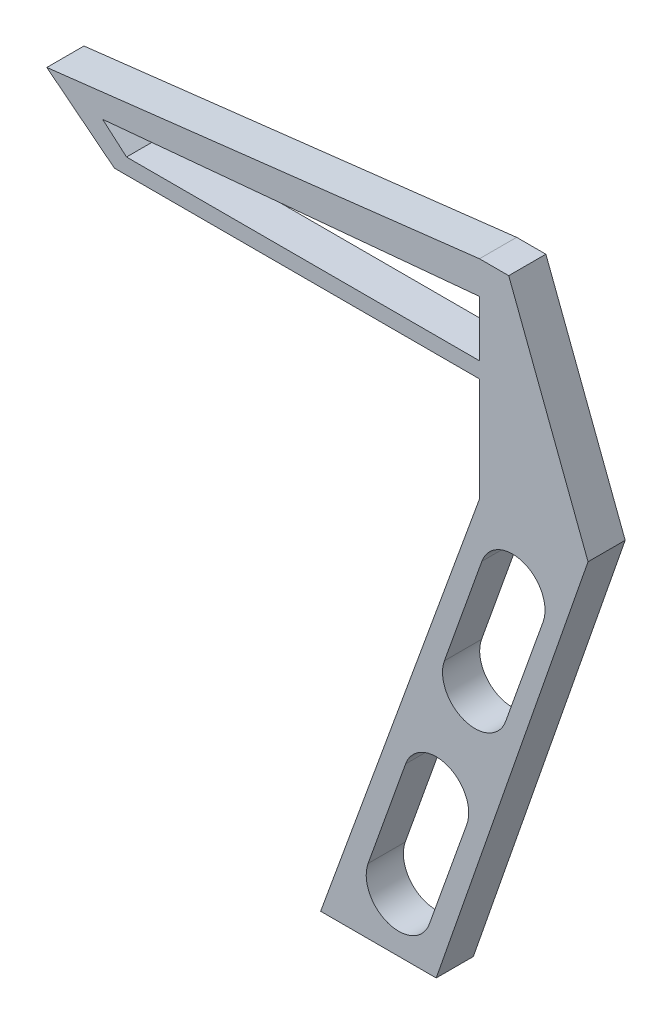
from build123d import *

# Parameters (mm, degrees)
BOSS_EXTRU_1_DEPTH = 20


with BuildPart() as part:
    # Esquisse1 → Boss.-Extru.1 (new body)
    with BuildSketch(Plane.XY):
        Polygon((-196.533735711, -8.457408384), (0, -8.457408384), (0, -64.477749577), (-85.505035831, -299.400904773), (-68.158030406, -299.400904773), (-23.296347582, -299.400904773), (58.442642683, -64.477749577), (15.742456943, 47.56293281), (0, 47.56293281), (-232.911164776, 20.29498163), (-207.234020919, 0), align=None)
        with BuildLine():
            ThreePointArc((-39.776845244, -207.826148347), (-17.410500422, -197.231497844), (-6.815849919, -219.597842666))
            Line((-6.815849919, -219.597842666), (-26.995897322, -276.102406082))
            ThreePointArc((-26.995897322, -276.102406082), (-49.362242144, -286.697056585), (-59.956892648, -264.330711763))
            Line((-59.956892648, -264.330711763), (-39.776845244, -207.826148347))
        make_face(mode=Mode.SUBTRACT)
        with BuildLine():
            ThreePointArc((1.304768326, -92.796753577), (23.671113149, -82.202103073), (34.265763652, -104.568447895))
            Line((34.265763652, -104.568447895), (14.085716249, -161.073011311))
            ThreePointArc((14.085716249, -161.073011311), (-8.280628573, -171.667661815), (-18.875279077, -149.301316992))
            Line((-18.875279077, -149.301316992), (1.304768326, -92.796753577))
        make_face(mode=Mode.SUBTRACT)
        Polygon((0, 30), (0, 0), (-190, 0), (-202.86096767, 11.137722401), align=None, mode=Mode.SUBTRACT)
    extrude(amount=BOSS_EXTRU_1_DEPTH)


solid = part.part
